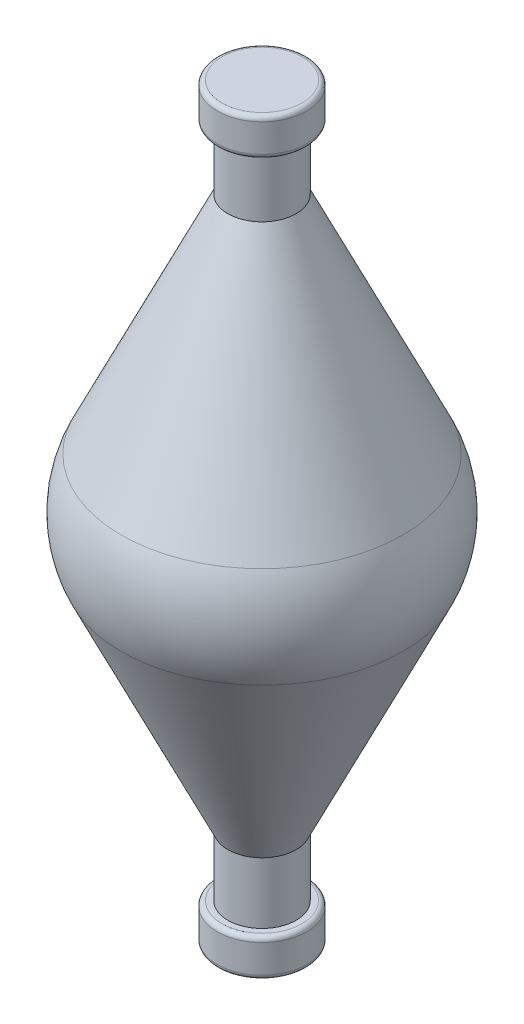
from build123d import *

# Parameters (mm, degrees)
CONG_1_R = 5
CONG_2_R = 0.2


with BuildPart() as part:
    # Esquisse1 → Révolution1 (revolve)
    with BuildSketch(Plane.XY, mode=Mode.PRIVATE) as r_volution1_sk:
        Polygon((0, 15.9), (0, -15.9), (1.9, -15.9), (1.9, -14.3), (1.45, -14.3), (1.45, -11.7), (7, 0), (1.45, 11.7), (1.45, 14.3), (1.9, 14.3), (1.9, 15.9), align=None)
    revolve(r_volution1_sk.sketch.rotate(Axis((0, 15.9, 0), (0, -1, 0)), 180), axis=Axis((0, 15.9, 0), (0, -1, 0)))  # turned: the seam where the file's is

    # Congé1
    cong_1_edges = [part.edges().sort_by_distance(p)[0] for p in [
        (7, 0, 0),
    ]]
    fillet(cong_1_edges, radius=CONG_1_R)

    # Congé2
    cong_2_edges = [part.edges().sort_by_distance(p)[0] for p in [
        (1.9, -14.3, 0),
        (1.9, 14.3, 0),
        (1.9, 15.9, 0),
        (1.9, -15.9, 0),
    ]]
    fillet(cong_2_edges, radius=CONG_2_R)


solid = part.part
